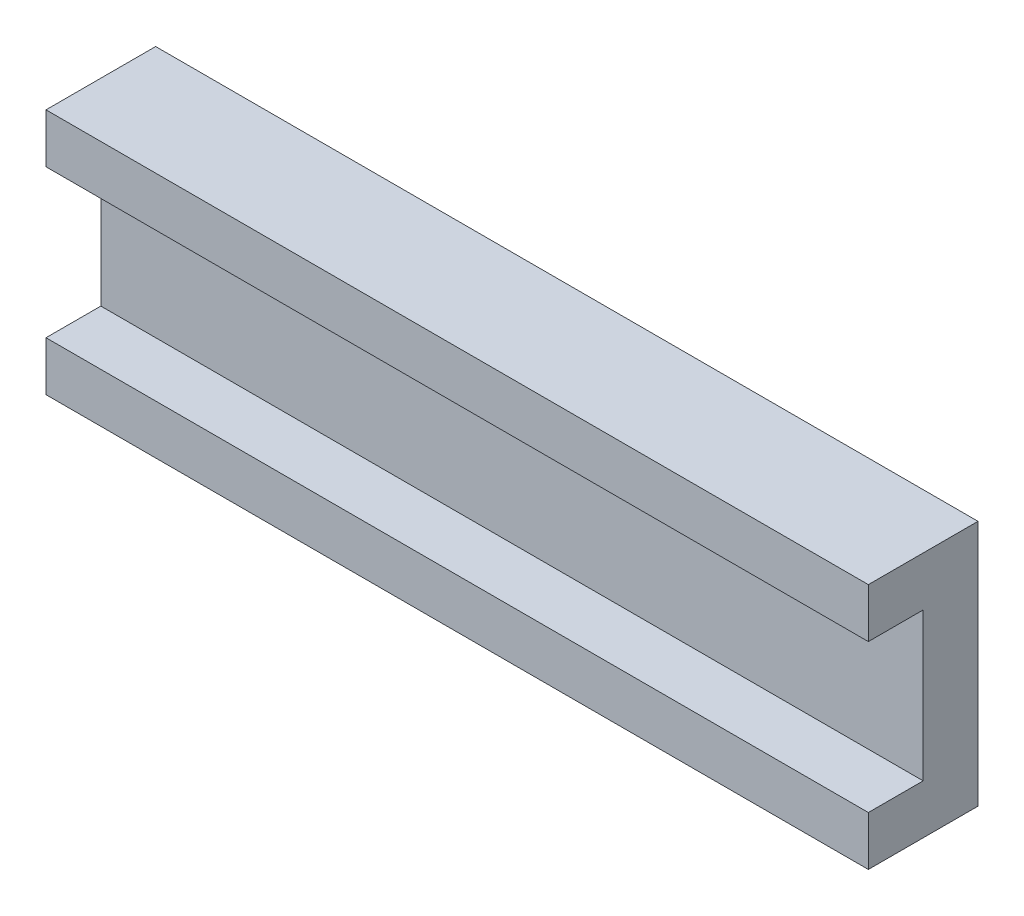
from build123d import *

# Parameters (mm, degrees)
SKETCH1_W           = 150
SKETCH1_H           = 45
BOSS_EXTRUDE1_DEPTH = 20
SKETCH2_W           = 150
SKETCH2_H           = 27
CUT_EXTRUDE1_DEPTH  = 10


with BuildPart() as part:
    # Sketch1 → Boss-Extrude1 (new body)
    with BuildSketch(Plane.XY):
        with Locations((-75, 22.5)):
            Rectangle(SKETCH1_W, SKETCH1_H)
    extrude(amount=BOSS_EXTRUDE1_DEPTH)

    # Sketch2 → Cut-Extrude1 (cut)
    with BuildSketch(Plane.XY.offset(20)):
        with Locations((-75, 22.5)):
            Rectangle(SKETCH2_W, SKETCH2_H)
    extrude(amount=-CUT_EXTRUDE1_DEPTH, mode=Mode.SUBTRACT)


solid = part.part
